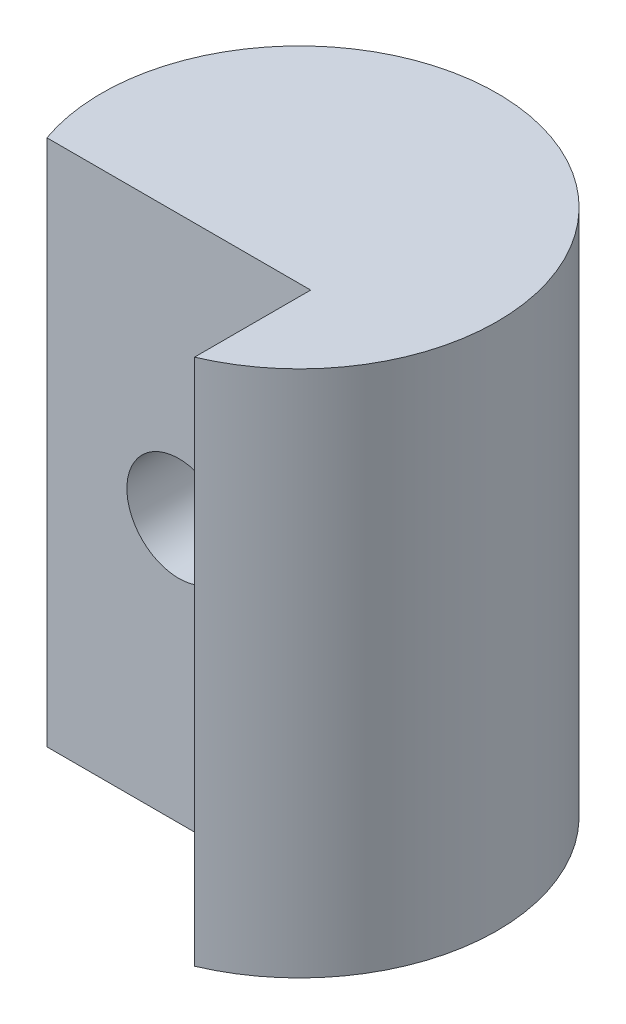
from build123d import *

# Parameters (mm, degrees)
PROFILE_SKETCH_R       = 4.7625
BOSS_EXTRUDE1_DEPTH    = 12.7
PLATE_RELIEF_CUT_REACH = 14.7
PLATE_RELIEF_SKETCH_W  = 6.35
PLATE_RELIEF_SKETCH_H  = 3.175
M3X0_5_TAPPED_HOLE1_D  = 2.5


with BuildPart() as part:
    # Profile Sketch → Boss-Extrude1 (new body)
    with BuildSketch(Plane(origin=(0, 0, 0), x_dir=(1, 0, 0), z_dir=(0, 1, 0))):
        Circle(PROFILE_SKETCH_R)
    extrude(amount=BOSS_EXTRUDE1_DEPTH)

    # Plate Relief Sketch → Plate Relief Cut (cut, up to next)
    with BuildSketch(Plane.XZ, mode=Mode.PRIVATE) as plate_relief_cut_sk1:
        with Locations((-1.315128061, 3.175)):
            Rectangle(PLATE_RELIEF_SKETCH_W, PLATE_RELIEF_SKETCH_H)
    plate_relief_cut_tool1 = extrude(plate_relief_cut_sk1.sketch, amount=-PLATE_RELIEF_CUT_REACH, mode=Mode.PRIVATE) & part.part
    add(plate_relief_cut_tool1.solids().sort_by_distance((-1.315128, 0, 3.175))[0], mode=Mode.SUBTRACT)

    # M3x0.5 Tapped Hole1 (through all)
    with Locations(Plane(origin=(-1.315128061, 6.35, 1.5875), x_dir=(1, 0, 0), z_dir=(0, 0, 1))):
        with Locations((0, 0)):
            Hole(M3X0_5_TAPPED_HOLE1_D / 2)


solid = part.part
